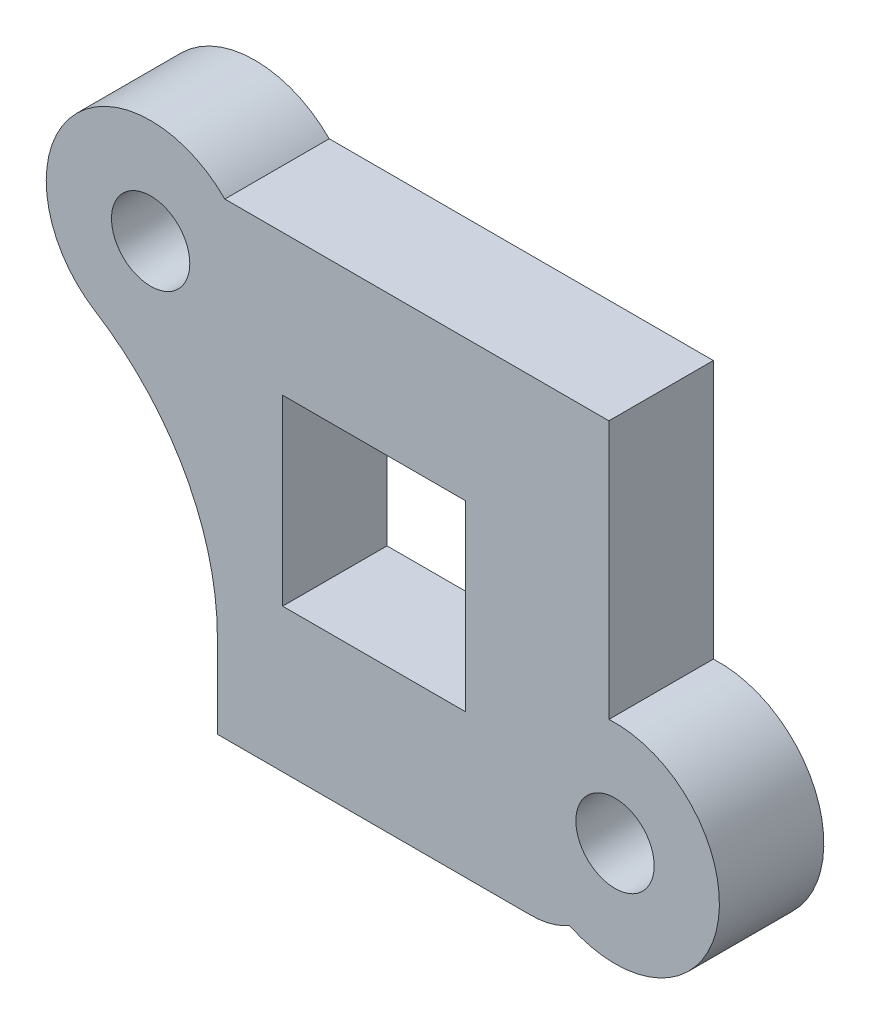
from build123d import *

# Parameters (mm, degrees)
SKETCH_1_R          = 1.5
SKETCH_1_W          = 7
SKETCH_1_H          = 7
EXTRUDE_1_DEPTH     = 4
CUT_EXTRUDE_1_DEPTH = 5
FILLET_1_R          = 10
CHAMFER_1_SIZE      = 1.5


with BuildPart() as part:
    # Эскиз1 → Бобышка-Вытянуть1 (new body)
    with BuildSketch(Plane.XY):
        with BuildLine():
            Line((7.5, -9.463206067), (-7.5, -9.463206067))
            Line((-7.5, -9.463206067), (-7.5, 3.572357891))
            ThreePointArc((-7.5, 3.572357891), (-14.05213631, 6.841981187), (-7.21473133, 9.463206067))
            Line((-7.21473133, 9.463206067), (7.5, 9.463206067))
            Line((7.5, 9.463206067), (7.5, -0.443591232))
            ThreePointArc((7.5, -0.443591232), (11.733092656, -4.436793933), (7.5, -8.429996634))
            Line((7.5, -8.429996634), (7.5, -9.463206067))
        make_face()
        with Locations((7.733092656, -4.436793933)):
            Circle(SKETCH_1_R, mode=Mode.SUBTRACT)
        with Locations((-10.056818182, 6.648504959)):
            Circle(SKETCH_1_R, mode=Mode.SUBTRACT)
        with Locations((-1.5, 0.563206067)):
            Rectangle(SKETCH_1_W, SKETCH_1_H, mode=Mode.SUBTRACT)
    extrude(amount=EXTRUDE_1_DEPTH)

    # Эскиз2 → Вырез-Вытянуть1 (cut, through all)
    with BuildSketch(Plane(origin=(0, 0, 0), x_dir=(-1, 0, 0), z_dir=(0, 0, -1))):
        with BuildLine():
            Line((7.5, -9.463206067), (-7.5, -9.463206067))
            Line((-7.5, -9.463206067), (-7.5, -8.429996634))
            ThreePointArc((-7.5, -8.429996634), (-6.727483224, -8.308324595), (-5.993405004, -8.038666623))
            ThreePointArc((-5.993405004, -8.038666623), (-5.272781318, -8.335553846), (-4.5, -8.436793933))
            Line((-4.5, -8.436793933), (7.5, -8.436793933))
            Line((7.5, -8.436793933), (7.5, -9.463206067))
        make_face()
    extrude(amount=-CUT_EXTRUDE_1_DEPTH, mode=Mode.SUBTRACT)

    # Скругление1
    fillet_1_edges = [part.edges().sort_by_distance(p)[0] for p in [
        (-7.5, 3.572357891, 2),
    ]]
    fillet(fillet_1_edges, radius=FILLET_1_R)

    # Фаска1
    chamfer_1_edges = [part.edges().sort_by_distance(p)[0] for p in [
        (6.233092656, -4.436793933, 0),
        (-11.556818182, 6.648504959, 0),
    ]]
    chamfer(chamfer_1_edges, length=CHAMFER_1_SIZE)


solid = part.part
